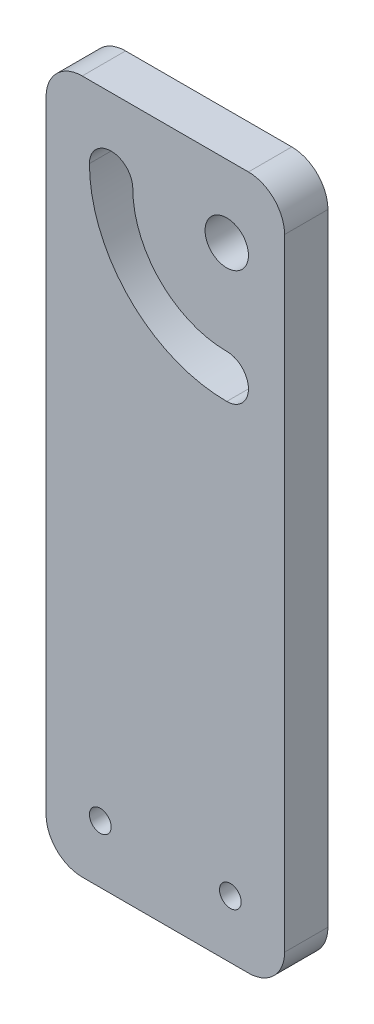
from build123d import *

# Parameters (mm, degrees)
ESBO_O1_R                = 3
ESBO_O1_R_2              = 1.5
RESSALTO_EXTRUS_O2_DEPTH = 6


with BuildPart() as part:
    # Esboço1 → Ressalto-extrusão2 (new body)
    with BuildSketch(Plane.XY):
        with BuildLine():
            Line((5, 50), (28, 50))
            ThreePointArc((28, 50), (31.535533906, 48.535533906), (33, 45))
            Line((33, 45), (33, -41))
            ThreePointArc((33, -41), (31.535533906, -44.535533906), (28, -46))
            Line((28, -46), (5, -46))
            ThreePointArc((5, -46), (1.464466094, -44.535533906), (0, -41))
            Line((0, -41), (0, 45))
            ThreePointArc((0, 45), (1.464466094, 48.535533906), (5, 50))
        make_face()
        with Locations((25, 40)):
            Circle(ESBO_O1_R, mode=Mode.SUBTRACT)
        with Locations((25.5, -38)):
            Circle(ESBO_O1_R_2, mode=Mode.SUBTRACT)
        with Locations((7.5, -38)):
            Circle(ESBO_O1_R_2, mode=Mode.SUBTRACT)
        with BuildLine():
            ThreePointArc((6, 40), (11.564971157, 26.564971157), (25, 21))
            ThreePointArc((25, 21), (28, 24), (25, 27))
            ThreePointArc((25, 27), (15.807611845, 30.807611845), (12, 40))
            ThreePointArc((12, 40), (9, 43), (6, 40))
        make_face(mode=Mode.SUBTRACT)
    extrude(amount=RESSALTO_EXTRUS_O2_DEPTH)


solid = part.part
